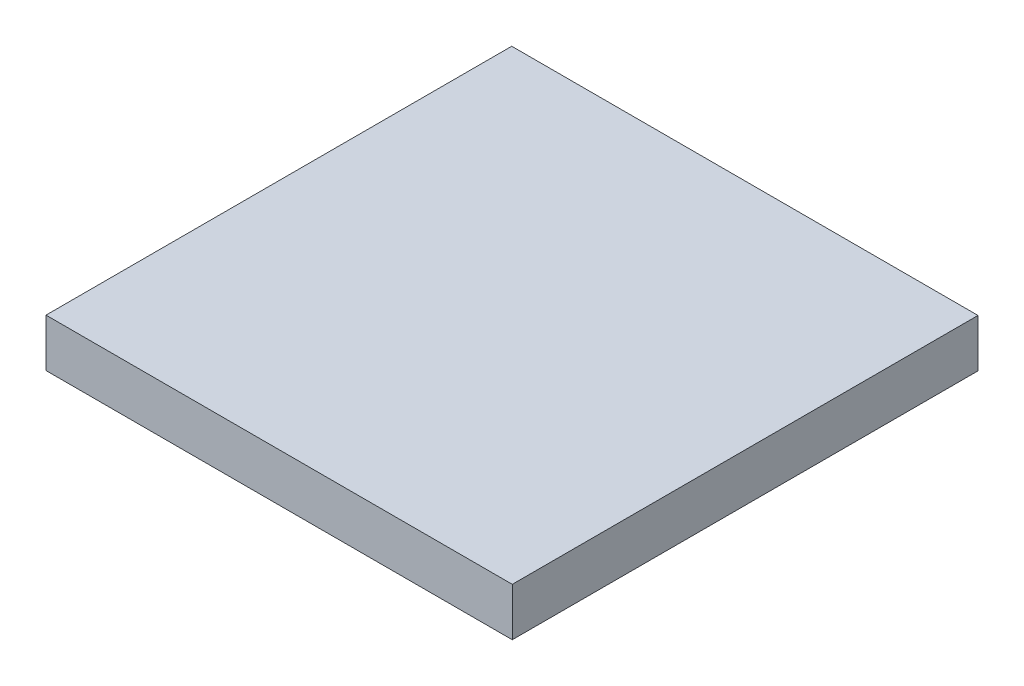
from build123d import *

# Parameters (mm, degrees)
SKETCH1_W           = 127.9906
SKETCH1_H           = 127.8382
BOSS_EXTRUDE1_DEPTH = 13.1826
SKETCH2_W           = 102.5906
SKETCH2_H           = 102.4382
CUT_EXTRUDE1_DEPTH  = 7.874
SKETCH3_R           = 1.27
CUT_EXTRUDE2_DEPTH  = 7.874
SKETCH4_W           = 15.7988
SKETCH4_H           = 8.2804
BOSS_EXTRUDE2_DEPTH = 9.8298
SKETCH5_W           = 8.89
SKETCH5_H           = 27.94
BOSS_EXTRUDE3_DEPTH = 7.874
SKETCH6_R           = 1.5113
BOSS_EXTRUDE4_DEPTH = 3.683
FILLET3_R           = 1.27
FILLET4_R           = 1.27
FILLET5_R           = 1.27
FILLET6_R           = 1.27
FILLET8_R           = 1.27
FILLET9_R           = 1.27


with BuildPart() as part:
    # Sketch1 → Boss-Extrude1 (new body)
    with BuildSketch(Plane(origin=(0, 0, 0), x_dir=(1, 0, 0), z_dir=(0, 1, 0))):
        with Locations((63.9953, 63.9191)):
            Rectangle(SKETCH1_W, SKETCH1_H)
    extrude(amount=BOSS_EXTRUDE1_DEPTH)

    # Sketch2 → Cut-Extrude1 (cut)
    with BuildSketch(Plane.XZ):
        with Locations((63.9953, -63.9191)):
            Rectangle(SKETCH2_W, SKETCH2_H)
    extrude(amount=-CUT_EXTRUDE1_DEPTH, mode=Mode.SUBTRACT)

    # Sketch3 → Cut-Extrude2 (cut)
    with BuildSketch(Plane.XZ):
        with Locations((8.255, -108.7882)):
            Circle(SKETCH3_R)
        with Locations((8.255, -19.05)):
            Circle(SKETCH3_R)
        with Locations((119.7356, -108.7882)):
            Circle(SKETCH3_R)
        with Locations((119.7356, -19.05)):
            Circle(SKETCH3_R)
    extrude(amount=-CUT_EXTRUDE2_DEPTH, mode=Mode.SUBTRACT)

    # Sketch4 → Boss-Extrude2 (add)
    with BuildSketch(Plane(origin=(0, 7.874, 0), x_dir=(-1, 0, 0), z_dir=(0, -1, 0))):
        with Locations((-42.4688, 72.9996)):
            Rectangle(SKETCH4_W, SKETCH4_H)
    extrude(amount=BOSS_EXTRUDE2_DEPTH)

    # Sketch5 → Boss-Extrude3 (add)
    with BuildSketch(Plane(origin=(0, 7.874, 0), x_dir=(-1, 0, 0), z_dir=(0, -1, 0))):
        with Locations((-17.7292, 65.9384)):
            Rectangle(SKETCH5_W, SKETCH5_H)
        with Locations((-110.2614, 65.9384)):
            Rectangle(SKETCH5_W, SKETCH5_H)
    extrude(amount=BOSS_EXTRUDE3_DEPTH)

    # Sketch6 → Boss-Extrude4 (add)
    with BuildSketch(Plane(origin=(0, 0, 0), x_dir=(-1, 0, 0), z_dir=(0, -1, 0))):
        with Locations((-23.4823, 118.7323)):
            Circle(SKETCH6_R)
        with Locations((-104.5083, 9.1059)):
            Circle(SKETCH6_R)
    extrude(amount=BOSS_EXTRUDE4_DEPTH)

    # Fillet3
    fillet3_edges = [part.edges().sort_by_distance(p)[0] for p in [
        (12.7, 3.937, -115.1382),
    ]]
    fillet(fillet3_edges, radius=FILLET3_R)

    # Fillet4
    fillet4_edges = [part.edges().sort_by_distance(p)[0] for p in [
        (12.7, 3.937, -12.7),
    ]]
    fillet(fillet4_edges, radius=FILLET4_R)

    # Fillet5
    fillet5_edges = [part.edges().sort_by_distance(p)[0] for p in [
        (115.2906, 3.937, -12.7),
    ]]
    fillet(fillet5_edges, radius=FILLET5_R)

    # Fillet6
    fillet6_edges = [part.edges().sort_by_distance(p)[0] for p in [
        (115.2906, 3.937, -115.1382),
    ]]
    fillet(fillet6_edges, radius=FILLET6_R)

    # Fillet8
    fillet8_edges = [part.edges().sort_by_distance(p)[0] for p in [
        (24.9936, -3.683, -118.7323),
    ]]
    fillet(fillet8_edges, radius=FILLET8_R)

    # Fillet9
    fillet9_edges = [part.edges().sort_by_distance(p)[0] for p in [
        (106.0196, -3.683, -9.1059),
    ]]
    fillet(fillet9_edges, radius=FILLET9_R)


solid = part.part
